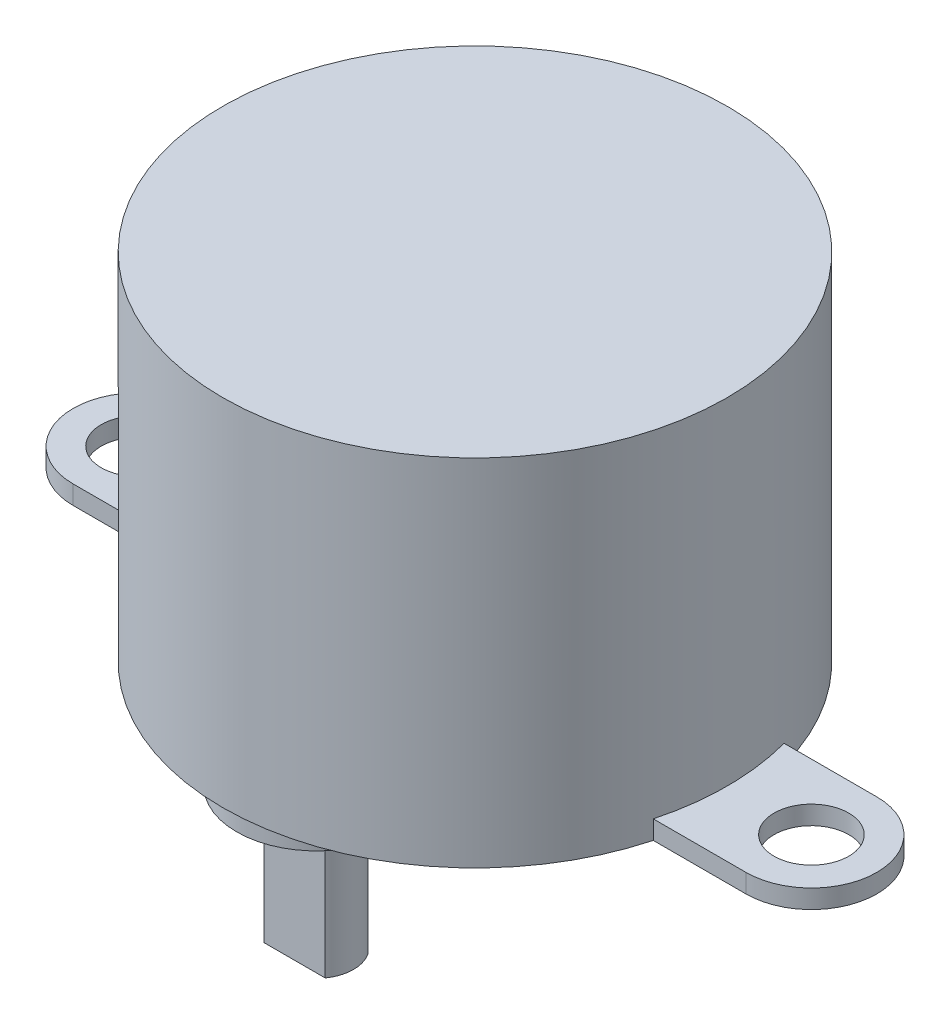
from build123d import *

# Parameters (mm, degrees)
SKETCH1_R           = 13.5
BOSS_EXTRUDE1_DEPTH = 19
SKETCH2_R           = 2
BOSS_EXTRUDE2_DEPTH = 1
SKETCH4_R           = 4.25
BOSS_EXTRUDE3_DEPTH = 1.5
SKETCH5_R           = 2
BOSS_EXTRUDE4_DEPTH = 1.5
BOSS_EXTRUDE5_DEPTH = 6


with BuildPart() as part:
    # Sketch1 → Boss-Extrude1 (new body)
    with BuildSketch(Plane(origin=(0, 0, 0), x_dir=(1, 0, 0), z_dir=(0, 1, 0))):
        Circle(SKETCH1_R)
    extrude(amount=BOSS_EXTRUDE1_DEPTH)

    # Sketch2 → Boss-Extrude2 (add)
    with BuildSketch(Plane.XZ):
        with BuildLine():
            Line((18, 3.5), (13.038405, 3.5))
            ThreePointArc((13.038405, 3.5), (13.5, 0), (13.038405, -3.5))
            Line((13.038405, -3.5), (18, -3.5))
            ThreePointArc((18, -3.5), (21.5, 0), (18, 3.5))
        make_face()
        with Locations((18, 0)):
            Circle(SKETCH2_R, mode=Mode.SUBTRACT)
    boss_extrude2 = extrude(amount=-BOSS_EXTRUDE2_DEPTH)

    # Mirror1: Boss-Extrude2 across plane
    add(boss_extrude2.mirror(Plane(origin=(0, 0, 0), x_dir=(0, 0, 1), z_dir=(1, 0, 0))))

    # Sketch4 → Boss-Extrude3 (add)
    with BuildSketch(Plane.XZ):
        with Locations((0, 8.5)):
            Circle(SKETCH4_R)
    extrude(amount=BOSS_EXTRUDE3_DEPTH)

    # Sketch5 → Boss-Extrude4 (add)
    with BuildSketch(Plane.XZ.offset(1.5)):
        with Locations((0, 8.5)):
            Circle(SKETCH5_R)
    extrude(amount=BOSS_EXTRUDE4_DEPTH)

    # Sketch6 → Boss-Extrude5 (add)
    with BuildSketch(Plane.XZ.offset(3)):
        with BuildLine():
            Line((-1.636307, 9.65), (1.636307, 9.65))
            ThreePointArc((1.636307, 9.65), (2, 8.5), (1.636307, 7.35))
            Line((1.636307, 7.35), (-1.636307, 7.35))
            ThreePointArc((-1.636307, 7.35), (-2, 8.5), (-1.636307, 9.65))
        make_face()
    extrude(amount=BOSS_EXTRUDE5_DEPTH)


solid = part.part
